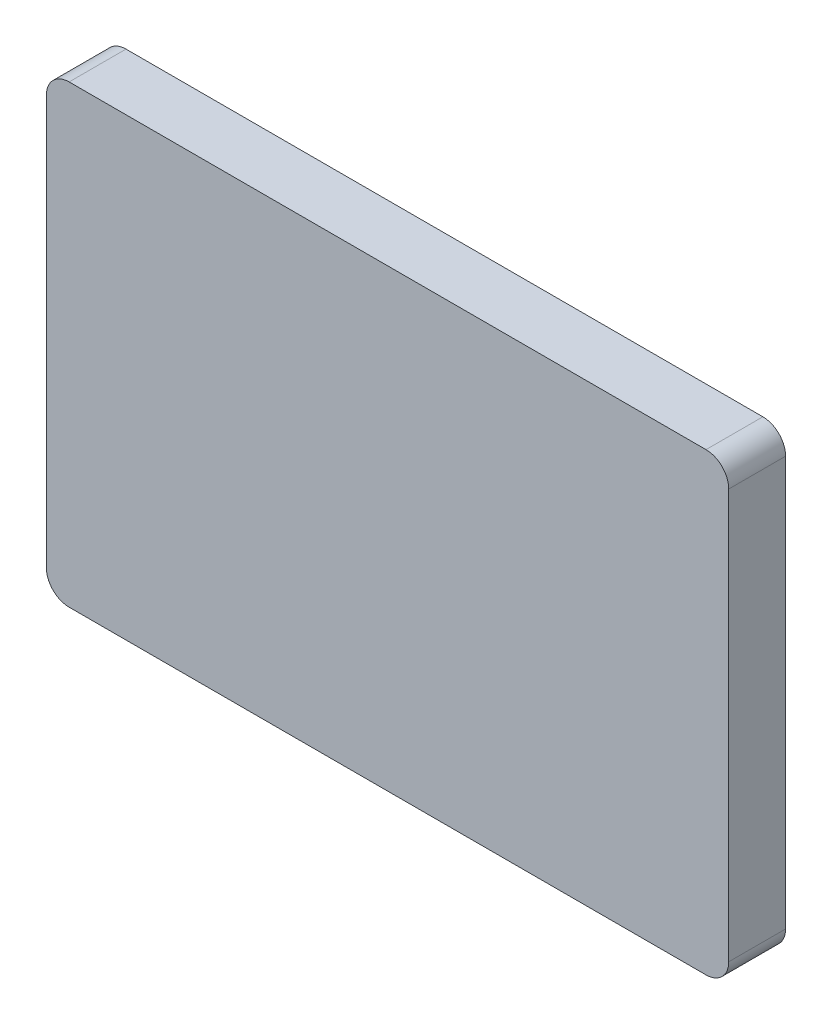
from build123d import *

# Parameters (mm, degrees)
SKETCH1_W           = 76.2
SKETCH1_H           = 50.8
BOSS_EXTRUDE1_DEPTH = 6.35
FILLET1_R           = 2.54


with BuildPart() as part:
    # Sketch1 → Boss-Extrude1 (new body)
    with BuildSketch(Plane.XY):
        Rectangle(SKETCH1_W, SKETCH1_H)
    extrude(amount=BOSS_EXTRUDE1_DEPTH)

    # Fillet1
    fillet1_edges = [part.edges().sort_by_distance(p)[0] for p in [
        (38.1, -25.4, 3.175),
        (-38.1, -25.4, 3.175),
        (-38.1, 25.4, 3.175),
        (38.1, 25.4, 3.175),
    ]]
    fillet(fillet1_edges, radius=FILLET1_R)


solid = part.part
